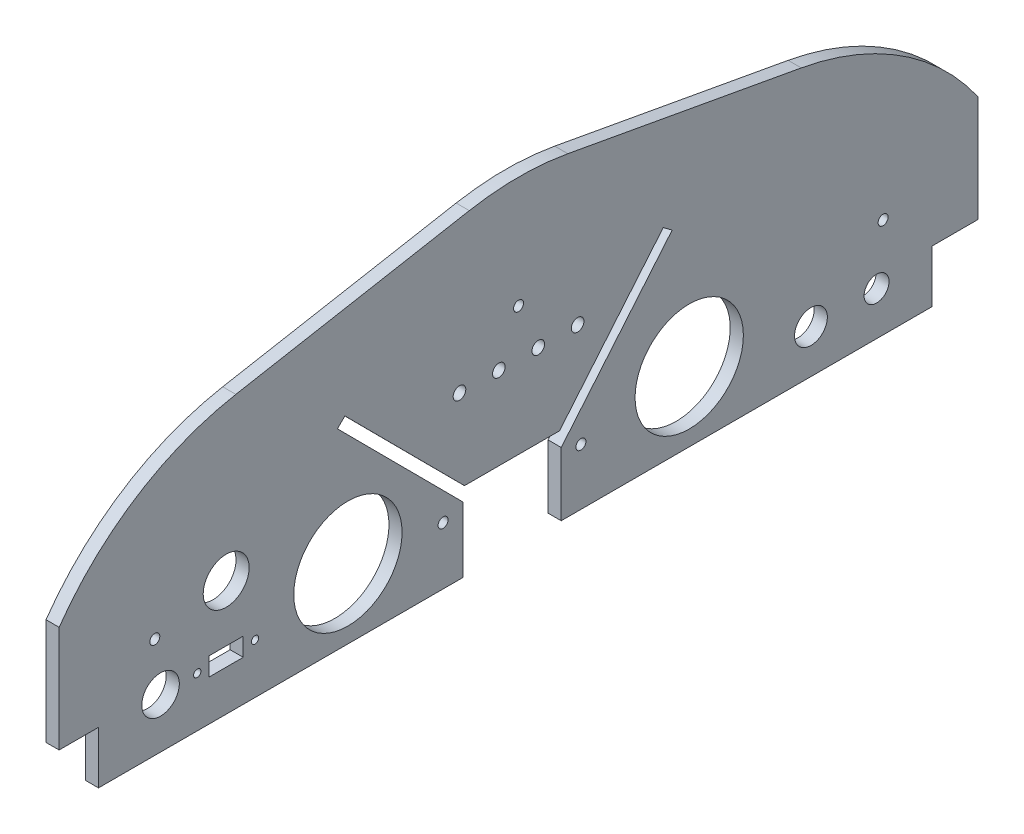
from build123d import *

# Parameters (mm, degrees)
BASE_DEPTH                 = 6.35
STEERING_SLOT_REACH        = 8.35
GAUGE_HOLES_REACH          = 8.35
SKETCH6_R                  = 26.19375
LED_HOLES_REACH            = 8.35
SKETCH7_R                  = 3.048
BUTTONS_AND_SWITCHES_REACH = 8.35
SKETCH8_R                  = 6.0325
SKETCH8_R_2                = 7.9375
SKETCH12_W                 = 16.51
SKETCH12_H                 = 8.89
SKETCH12_R                 = 9.0805
SKETCH12_R_2               = 1.778
SKETCH12_R_3               = 11.1125
CONNECTORS_DEPTH           = 7.35
MOUNTING_HOLES_REACH       = 8.35
SKETCH4_R                  = 2.413


with BuildPart() as part:
    # Sketch1 → Base (new body)
    with BuildSketch(Plane(origin=(0, 0, 0), x_dir=(0, 0, -1), z_dir=(1, 0, 0))):
        with BuildLine():
            Line((200.025, 53.34), (222.25, 53.34))
            Line((222.25, 53.34), (222.25, 104.759436362))
            ThreePointArc((222.25, 104.759436362), (184.933257597, 140.638851516), (136.764676181, 159.603541333))
            Line((136.764676181, 159.603541333), (23.838528544, 180.121479943))
            ThreePointArc((23.838528544, 180.121479943), (0, 182.269547576), (-23.838528544, 180.121479943))
            Line((-23.838528544, 180.121479943), (-136.764676181, 159.603541333))
            ThreePointArc((-136.764676181, 159.603541333), (-184.933257597, 140.638851516), (-222.25, 104.759436362))
            Line((-222.25, 104.759436362), (-222.25, 53.34))
            Line((-222.25, 53.34), (-203.2, 53.34))
            Line((-203.2, 53.34), (-203.2, 27.94))
            Line((-203.2, 27.94), (200.025, 27.94))
            Line((200.025, 27.94), (200.025, 53.34))
        make_face()
    extrude(amount=BASE_DEPTH)

    # Sketch5 → Steering Slot (cut, up to next)
    with BuildSketch(Plane.ZY, mode=Mode.PRIVATE) as steering_slot_sk1:
        Polygon((26.9875, -568.360061952), (26.9875, 27.94), (26.9875, 59.672795533), (87.620103077, 120.603017139), (84.019216986, 124.186314414), (26.156922884, 66.04), (-19.828021448, 66.04), (-69.999330873, 126.106684486), (-74.2969186, 122.888561577), (-20.6375, 58.645802045), (-20.6375, 27.94), (-20.6375, -568.360061952), (-20.6375, -1760.960185856), (26.9875, -1760.960185856), align=None)
    steering_slot_tool1 = extrude(steering_slot_sk1.sketch, amount=-STEERING_SLOT_REACH, mode=Mode.PRIVATE) & part.part
    add(steering_slot_tool1.solids().sort_by_distance((0, -838.304281, 3.188606))[0], mode=Mode.SUBTRACT)

    # Sketch6 → Gauge Holes (cut, up to next)
    with BuildSketch(Plane.ZY, mode=Mode.PRIVATE) as gauge_holes_sk1:
        with Locations((-82.55, 61.619547576)):
            Circle(SKETCH6_R)
    gauge_holes_tool1 = extrude(gauge_holes_sk1.sketch, amount=-GAUGE_HOLES_REACH, mode=Mode.PRIVATE) & part.part
    add(gauge_holes_tool1.solids().sort_by_distance((0, 61.619548, -82.55))[0], mode=Mode.SUBTRACT)
    # Sketch6 → Gauge Holes (cut, up to next)
    with BuildSketch(Plane.ZY, mode=Mode.PRIVATE) as gauge_holes_sk2:
        with Locations((82.55, 61.619547576)):
            Circle(SKETCH6_R)
    gauge_holes_tool2 = extrude(gauge_holes_sk2.sketch, amount=-GAUGE_HOLES_REACH, mode=Mode.PRIVATE) & part.part
    add(gauge_holes_tool2.solids().sort_by_distance((0, 61.619548, 82.55))[0], mode=Mode.SUBTRACT)

    # Sketch7 → LED Holes (cut, up to next)
    with BuildSketch(Plane.ZY, mode=Mode.PRIVATE) as led_holes_sk1:
        with Locations((-28.575, 106.069547576)):
            Circle(SKETCH7_R)
    led_holes_tool1 = extrude(led_holes_sk1.sketch, amount=-LED_HOLES_REACH, mode=Mode.PRIVATE) & part.part
    add(led_holes_tool1.solids().sort_by_distance((0, 106.069548, -28.575))[0], mode=Mode.SUBTRACT)
    # Sketch7 → LED Holes (cut, up to next)
    with BuildSketch(Plane.ZY, mode=Mode.PRIVATE) as led_holes_sk2:
        with Locations((-9.525, 106.069547576)):
            Circle(SKETCH7_R)
    led_holes_tool2 = extrude(led_holes_sk2.sketch, amount=-LED_HOLES_REACH, mode=Mode.PRIVATE) & part.part
    add(led_holes_tool2.solids().sort_by_distance((0, 106.069548, -9.525))[0], mode=Mode.SUBTRACT)
    # Sketch7 → LED Holes (cut, up to next)
    with BuildSketch(Plane.ZY, mode=Mode.PRIVATE) as led_holes_sk3:
        with Locations((9.525, 106.069547576)):
            Circle(SKETCH7_R)
    led_holes_tool3 = extrude(led_holes_sk3.sketch, amount=-LED_HOLES_REACH, mode=Mode.PRIVATE) & part.part
    add(led_holes_tool3.solids().sort_by_distance((0, 106.069548, 9.525))[0], mode=Mode.SUBTRACT)
    # Sketch7 → LED Holes (cut, up to next)
    with BuildSketch(Plane.ZY, mode=Mode.PRIVATE) as led_holes_sk4:
        with Locations((28.575, 106.069547576)):
            Circle(SKETCH7_R)
    led_holes_tool4 = extrude(led_holes_sk4.sketch, amount=-LED_HOLES_REACH, mode=Mode.PRIVATE) & part.part
    add(led_holes_tool4.solids().sort_by_distance((0, 106.069548, 28.575))[0], mode=Mode.SUBTRACT)

    # Sketch8 → Buttons and Switches (cut, up to next)
    with BuildSketch(Plane.ZY, mode=Mode.PRIVATE) as buttons_and_switches_sk1:
        with Locations((-173.189372644, 48.919547576)):
            Circle(SKETCH8_R)
    buttons_and_switches_tool1 = extrude(buttons_and_switches_sk1.sketch, amount=-BUTTONS_AND_SWITCHES_REACH, mode=Mode.PRIVATE) & part.part
    add(buttons_and_switches_tool1.solids().sort_by_distance((0, 48.919548, -173.189373))[0], mode=Mode.SUBTRACT)
    # Sketch8 → Buttons and Switches (cut, up to next)
    with BuildSketch(Plane.ZY, mode=Mode.PRIVATE) as buttons_and_switches_sk2:
        with Locations((-141.439372644, 48.919547576)):
            Circle(SKETCH8_R_2)
    buttons_and_switches_tool2 = extrude(buttons_and_switches_sk2.sketch, amount=-BUTTONS_AND_SWITCHES_REACH, mode=Mode.PRIVATE) & part.part
    add(buttons_and_switches_tool2.solids().sort_by_distance((0, 48.919548, -141.439373))[0], mode=Mode.SUBTRACT)

    # Sketch12 → Connectors (cut, through all)
    with BuildSketch(Plane.ZY):
        with Locations((141.439372644, 52.094547576)):
            Rectangle(SKETCH12_W, SKETCH12_H)
        with Locations((173.189372644, 52.094547576)):
            Circle(SKETCH12_R)
        with Locations((127.469372644, 52.094547576)):
            Circle(SKETCH12_R_2)
        with Locations((155.409372644, 52.094547576)):
            Circle(SKETCH12_R_2)
        with Locations((141.439372644, 83.844547576)):
            Circle(SKETCH12_R_3)
    extrude(amount=-CONNECTORS_DEPTH, mode=Mode.SUBTRACT)

    # Sketch4 → Mounting Holes (cut, up to next)
    with BuildSketch(Plane.ZY, mode=Mode.PRIVATE) as mounting_holes_sk1:
        with Locations((0, 128.294547576)):
            Circle(SKETCH4_R)
    mounting_holes_tool1 = extrude(mounting_holes_sk1.sketch, amount=-MOUNTING_HOLES_REACH, mode=Mode.PRIVATE) & part.part
    add(mounting_holes_tool1.solids().sort_by_distance((0, 128.294548, 0))[0], mode=Mode.SUBTRACT)
    # Sketch4 → Mounting Holes (cut, up to next)
    with BuildSketch(Plane.ZY, mode=Mode.PRIVATE) as mounting_holes_sk2:
        with Locations((-176.349882841, 76.128126101)):
            Circle(SKETCH4_R)
    mounting_holes_tool2 = extrude(mounting_holes_sk2.sketch, amount=-MOUNTING_HOLES_REACH, mode=Mode.PRIVATE) & part.part
    add(mounting_holes_tool2.solids().sort_by_distance((0, 76.128126, -176.349883))[0], mode=Mode.SUBTRACT)
    # Sketch4 → Mounting Holes (cut, up to next)
    with BuildSketch(Plane.ZY, mode=Mode.PRIVATE) as mounting_holes_sk3:
        with Locations((175.955527271, 76.647727234)):
            Circle(SKETCH4_R)
    mounting_holes_tool3 = extrude(mounting_holes_sk3.sketch, amount=-MOUNTING_HOLES_REACH, mode=Mode.PRIVATE) & part.part
    add(mounting_holes_tool3.solids().sort_by_distance((0, 76.647727, 175.955527))[0], mode=Mode.SUBTRACT)
    # Sketch4 → Mounting Holes (cut, up to next)
    with BuildSketch(Plane.ZY, mode=Mode.PRIVATE) as mounting_holes_sk4:
        with Locations((-30.1625, 55.191155375)):
            Circle(SKETCH4_R)
    mounting_holes_tool4 = extrude(mounting_holes_sk4.sketch, amount=-MOUNTING_HOLES_REACH, mode=Mode.PRIVATE) & part.part
    add(mounting_holes_tool4.solids().sort_by_distance((0, 55.191155, -30.1625))[0], mode=Mode.SUBTRACT)
    # Sketch4 → Mounting Holes (cut, up to next)
    with BuildSketch(Plane.ZY, mode=Mode.PRIVATE) as mounting_holes_sk5:
        with Locations((36.5125, 55.74106481)):
            Circle(SKETCH4_R)
    mounting_holes_tool5 = extrude(mounting_holes_sk5.sketch, amount=-MOUNTING_HOLES_REACH, mode=Mode.PRIVATE) & part.part
    add(mounting_holes_tool5.solids().sort_by_distance((0, 55.741065, 36.5125))[0], mode=Mode.SUBTRACT)


solid = part.part
